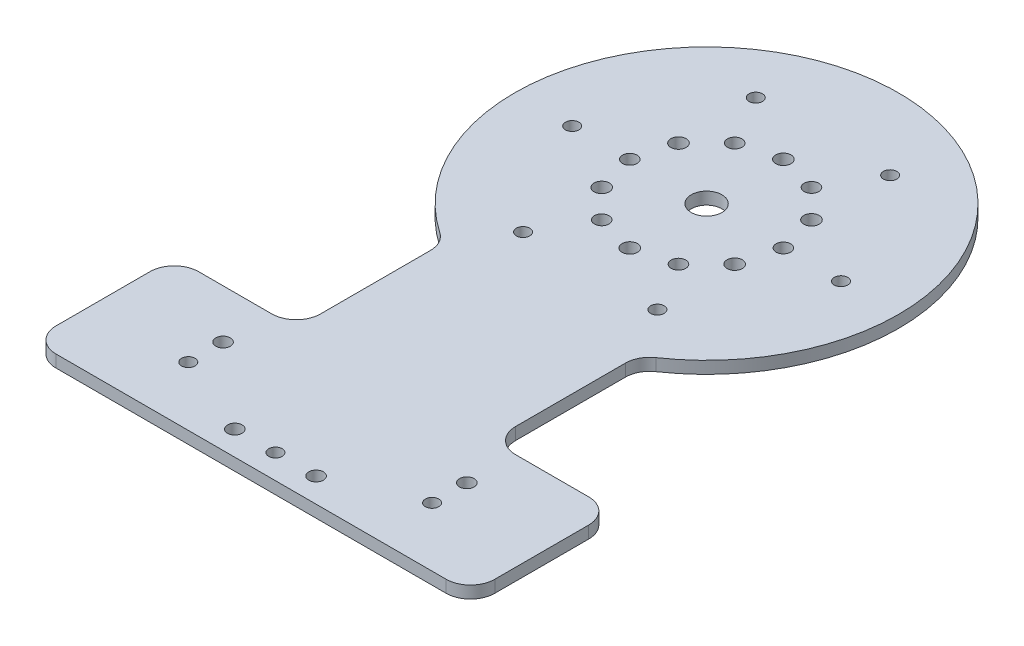
from build123d import *

# Parameters (mm, degrees)
SKETCH1_W           = 300
SKETCH1_H           = 200
BOSS_EXTRUDE1_DEPTH = 3.175
SKETCH6_R           = 4
CUT_EXTRUDE2_DEPTH  = 4.175
FILLET1_R           = 6.35
SKETCH2_R           = 1.5
CUT_EXTRUDE1_DEPTH  = 4.175
SKETCH16_R          = 1.89865
M5_THROUGH_DEPTH    = 4.175
SKETCH9_R           = 1.75
SKETCH9_R_2         = 1.89865
CUT_EXTRUDE3_DEPTH  = 4.175
SKETCH10_R          = 1.89865
SKETCH10_R_2        = 1.9939
CUT_EXTRUDE5_DEPTH  = 4.175
SKETCH17_R          = 1.75
M3_THROUGH_DEPTH    = 4.175
FILLET2_R           = 6.35


with BuildPart() as part:
    # Sketch1 → Boss-Extrude1 (new body)
    with BuildSketch(Plane(origin=(0, 0, 0), x_dir=(1, 0, 0), z_dir=(0, 1, 0))):
        with Locations((150, 100)):
            Rectangle(SKETCH1_W, SKETCH1_H)
    extrude(amount=BOSS_EXTRUDE1_DEPTH)

    # Sketch6 → Cut-Extrude2 (cut, through all)
    with BuildSketch(Plane(origin=(0, 3.175, 0), x_dir=(1, 0, 0), z_dir=(0, 1, 0))):
        with Locations((150, 118.651)):
            Circle(SKETCH6_R)
    extrude(amount=-CUT_EXTRUDE2_DEPTH, mode=Mode.SUBTRACT)

    # Fillet1
    fillet1_edges = [part.edges().sort_by_distance(p)[0] for p in [
        (0, 1.5875, -200),
        (300, 1.5875, -200),
        (300, 1.5875, 0),
        (0, 1.5875, 0),
    ]]
    fillet(fillet1_edges, radius=FILLET1_R)

    # Sketch2 → Cut-Extrude1 (cut, through all)
    with BuildSketch(Plane(origin=(0, 3.175, 0), x_dir=(1, 0, 0), z_dir=(0, 1, 0))):
        with Locations((6.35, 174.6)):
            Circle(SKETCH2_R)
        with Locations((6.35, 49.9999)):
            Circle(SKETCH2_R)
        with Locations((249.2, 75.3999)):
            Circle(SKETCH2_R)
        with Locations((50.8, 75.3999)):
            Circle(SKETCH2_R)
        with Locations((293.65, 49.9999)):
            Circle(SKETCH2_R)
        with Locations((50.8, 24.5999)):
            Circle(SKETCH2_R)
        with Locations((249.2, 24.5999)):
            Circle(SKETCH2_R)
        with Locations((25.4, 193.65)):
            Circle(SKETCH2_R)
        with Locations((274.6, 193.65)):
            Circle(SKETCH2_R)
        with Locations((293.65, 174.6)):
            Circle(SKETCH2_R)
    extrude(amount=-CUT_EXTRUDE1_DEPTH, mode=Mode.SUBTRACT)

    # Sketch16 → M5_through (cut, through all)
    with BuildSketch(Plane(origin=(0, 3.175, -5.8), x_dir=(1, 0, 0), z_dir=(0, -1, 0))):
        with Locations((118.25, -18.651)):
            Circle(SKETCH16_R)
        with Locations((139.416666667, -0.55096)):
            Circle(SKETCH16_R)
        with Locations((160.583333333, -0.55096)):
            Circle(SKETCH16_R)
        with Locations((181.75, -18.651)):
            Circle(SKETCH16_R)
    extrude(amount=M5_THROUGH_DEPTH, mode=Mode.SUBTRACT)

    # Sketch9 → Cut-Extrude3 (cut, through all)
    with BuildSketch(Plane(origin=(0, 3.175, 0), x_dir=(-1, 0, 0), z_dir=(0, 1, 0))):
        with Locations((-118.25, -15.40098)):
            Circle(SKETCH9_R)
        with Locations((-150, -6.35096)):
            Circle(SKETCH9_R)
        with Locations((-181.75, -15.40098)):
            Circle(SKETCH9_R)
        with Locations((-160.583333333, -6.35096)):
            Circle(SKETCH9_R_2)
    extrude(amount=-CUT_EXTRUDE3_DEPTH, mode=Mode.SUBTRACT)

    # Sketch10 → Cut-Extrude5 (cut, through all)
    with BuildSketch(Plane(origin=(0, 3.175, 0), x_dir=(1, 0, 0), z_dir=(0, 1, 0))):
        with Locations((160, 135.971508076)):
            Circle(SKETCH10_R)
        with Locations((150, 138.651)):
            Circle(SKETCH10_R_2)
        with Locations((167.320508076, 128.651)):
            Circle(SKETCH10_R_2)
        with Locations((167.320508076, 108.651)):
            Circle(SKETCH10_R_2)
        with Locations((150, 98.651)):
            Circle(SKETCH10_R_2)
        with Locations((132.679491924, 108.651)):
            Circle(SKETCH10_R_2)
        with Locations((132.679491924, 128.651)):
            Circle(SKETCH10_R_2)
        with Locations((170, 118.651)):
            Circle(SKETCH10_R)
        with Locations((160, 101.330491924)):
            Circle(SKETCH10_R)
        with Locations((140, 101.330491924)):
            Circle(SKETCH10_R)
        with Locations((130, 118.651)):
            Circle(SKETCH10_R)
        with Locations((140, 135.971508076)):
            Circle(SKETCH10_R)
        with BuildLine():
            Line((124.6, 75.583146559), (124.6, 37.151))
            Line((124.6, 37.151), (92.85, 37.151))
            Line((92.85, 37.151), (92.85, 0))
            Line((92.85, 0), (0, 0))
            Line((0, 0), (0, 200))
            Line((0, 200), (300, 200))
            Line((300, 200), (300, 0))
            Line((300, 0), (207.15, 0))
            Line((207.15, 0), (207.15, 37.151))
            Line((207.15, 37.151), (175.4, 37.151))
            Line((175.4, 37.151), (175.4, 75.583146559))
            ThreePointArc((175.4, 75.583146559), (150, 168.651), (124.6, 75.583146559))
        make_face()
    extrude(amount=-CUT_EXTRUDE5_DEPTH, mode=Mode.SUBTRACT)

    # Sketch17 → M3-through (cut, through all)
    with BuildSketch(Plane(origin=(0, 3.175, 0), x_dir=(1, 0, 0), z_dir=(0, 1, 0))):
        with Locations((185, 118.651)):
            Circle(SKETCH17_R)
        with Locations((167.5, 88.340110868)):
            Circle(SKETCH17_R)
        with Locations((132.5, 88.340110868)):
            Circle(SKETCH17_R)
        with Locations((115, 118.651)):
            Circle(SKETCH17_R)
        with Locations((132.5, 148.961889132)):
            Circle(SKETCH17_R)
        with Locations((167.5, 148.961889132)):
            Circle(SKETCH17_R)
    extrude(amount=-M3_THROUGH_DEPTH, mode=Mode.SUBTRACT)

    # Fillet2
    fillet2_edges = [part.edges().sort_by_distance(p)[0] for p in [
        (175.4, 1.5875, -75.583146559),
        (124.6, 1.5875, -75.583146559),
        (124.6, 1.5875, -37.151),
        (92.85, 1.5875, -37.151),
        (92.85, 1.5875, 0),
        (207.15, 1.5875, 0),
        (207.15, 1.5875, -37.151),
        (175.4, 1.5875, -37.151),
    ]]
    fillet(fillet2_edges, radius=FILLET2_R)


solid = part.part
